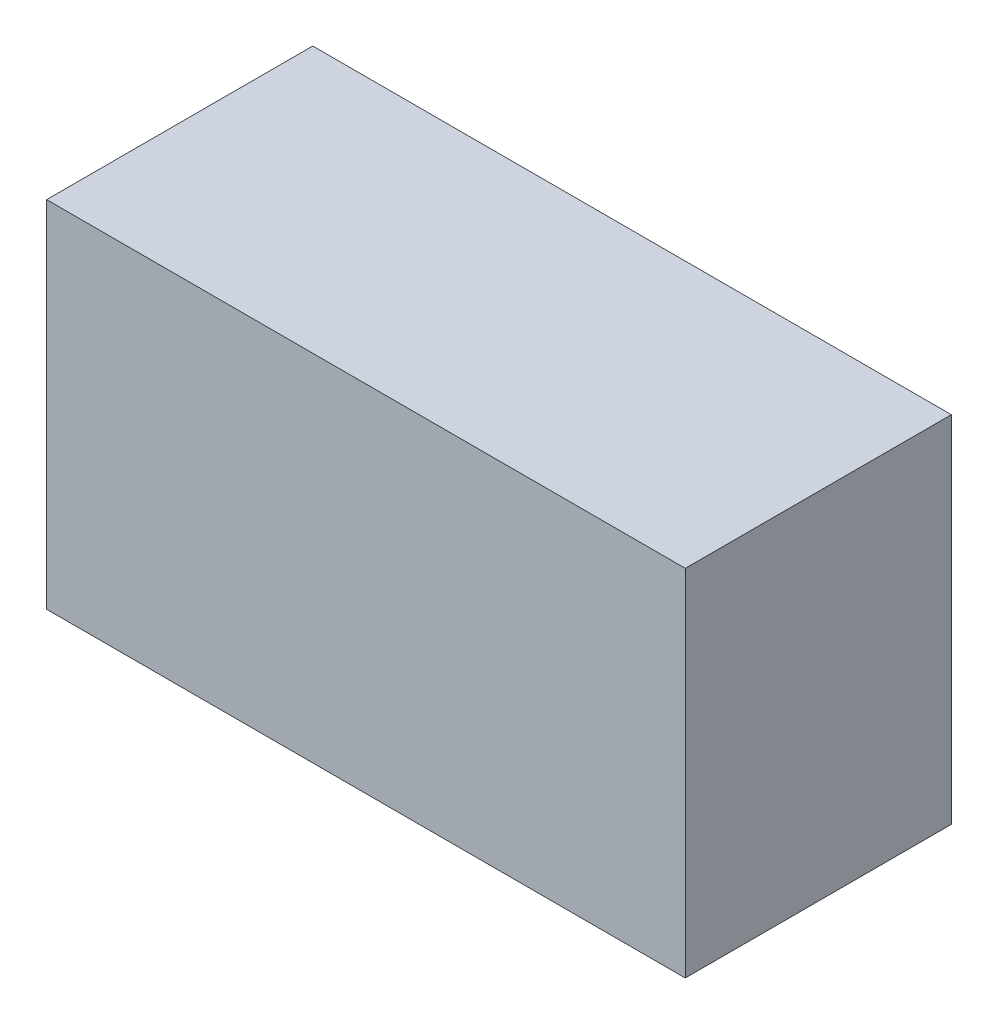
from build123d import *

# Parameters (mm, degrees)
SKETCH2_W           = 36
SKETCH2_H           = 20
BOSS_EXTRUDE1_DEPTH = 15


with BuildPart() as part:
    # Sketch2 → Boss-Extrude1 (new body)
    with BuildSketch(Plane.XY):
        with Locations((1.654411765, -0.205882353)):
            Rectangle(SKETCH2_W, SKETCH2_H)
    extrude(amount=BOSS_EXTRUDE1_DEPTH)


solid = part.part
